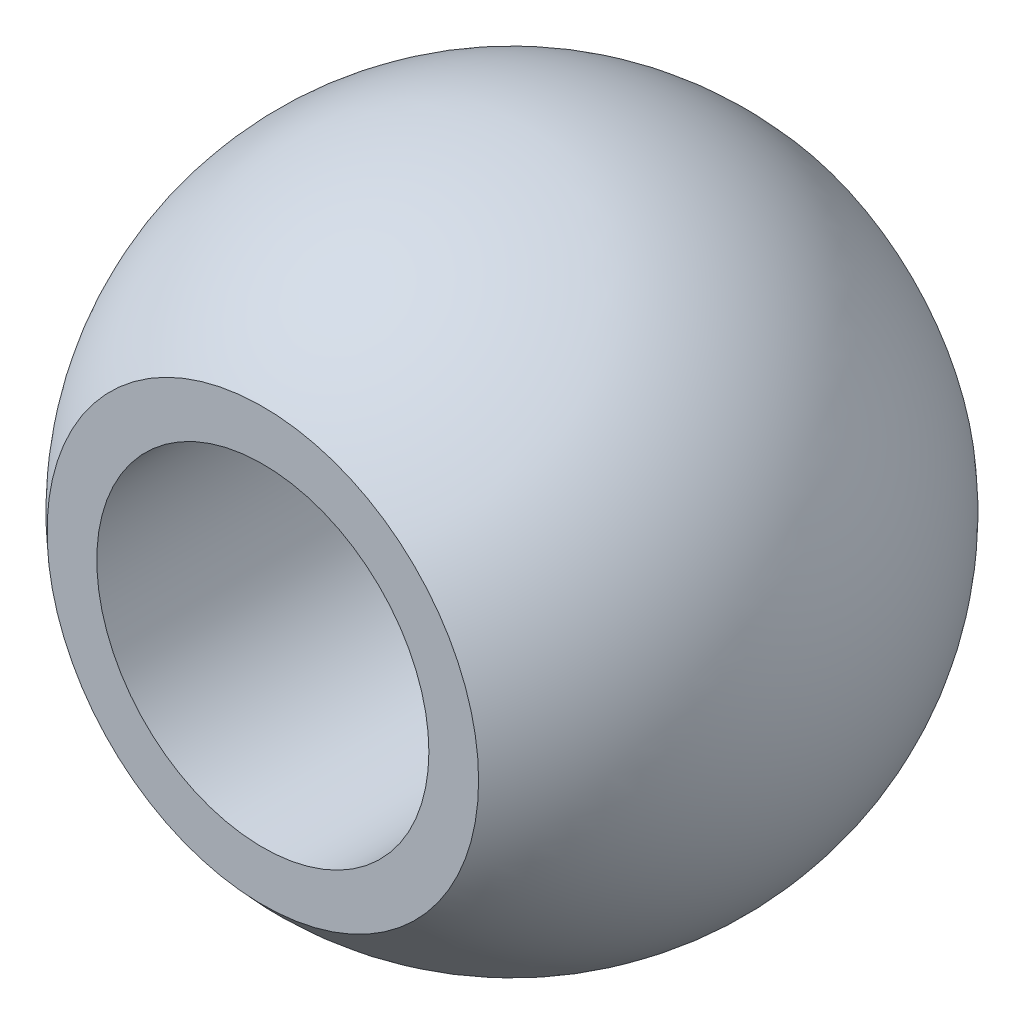
from build123d import *


with BuildPart() as part:
    # Sketch1 → Revolve1 (revolve)
    with BuildSketch(Plane(origin=(0, 0, 0), x_dir=(0, 0, -1), z_dir=(1, 0, 0))):
        with BuildLine():
            Line((-6, 5.197291987), (-6, 4))
            Line((-6, 4), (6, 4))
            Line((6, 4), (6, 5.197291987))
            ThreePointArc((6, 5.197291987), (0, 7.938), (-6, 5.197291987))
        make_face()
    revolve(axis=Axis((0, 0, 31.258955331), (0, 0, -1)))


solid = part.part
